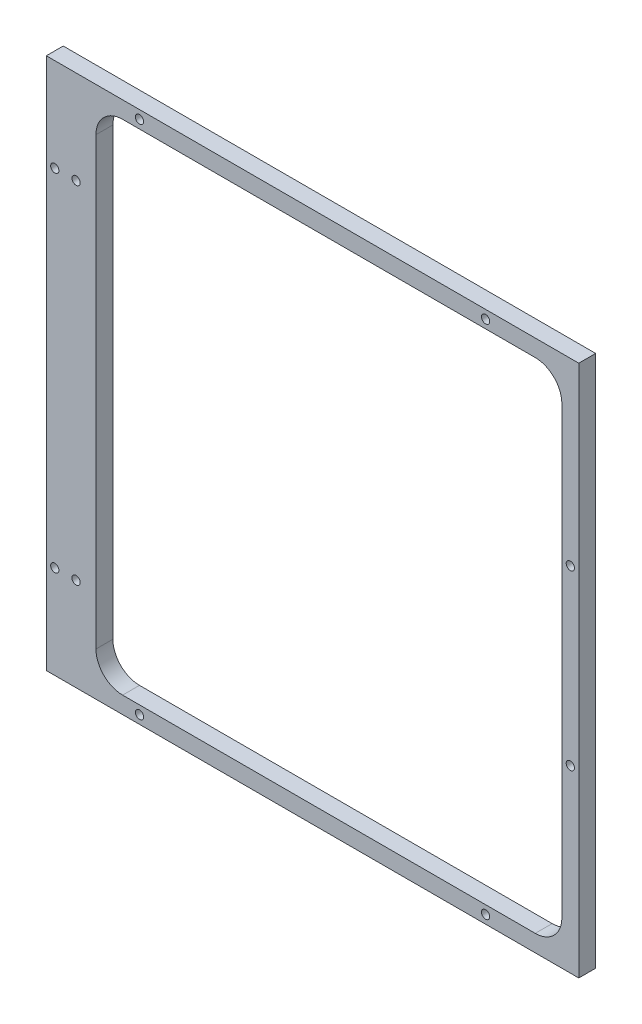
from build123d import *

# Parameters (mm, degrees)
SKETCH1_W           = 200
SKETCH1_H           = 200
BOSS_EXTRUDE1_DEPTH = 6.35
CUT_EXTRUDE1_DEPTH  = 6.35
SKETCH3_R           = 1.55
CUT_EXTRUDE2_DEPTH  = 6.35


with BuildPart() as part:
    # Sketch1 → Boss-Extrude1 (new body)
    with BuildSketch(Plane.XY):
        Rectangle(SKETCH1_W, SKETCH1_H)
    extrude(amount=BOSS_EXTRUDE1_DEPTH)

    # Sketch2 → Cut-Extrude1 (cut)
    with BuildSketch(Plane.XY.offset(6.35)):
        with BuildLine():
            Line((83.65, 93.65), (-71.35, 93.65))
            ThreePointArc((-71.35, 93.65), (-78.421067812, 90.721067812), (-81.35, 83.65))
            Line((-81.35, 83.65), (-81.35, -83.65))
            ThreePointArc((-81.35, -83.65), (-78.421067812, -90.721067812), (-71.35, -93.65))
            Line((-71.35, -93.65), (83.65, -93.65))
            ThreePointArc((83.65, -93.65), (90.721067812, -90.721067812), (93.65, -83.65))
            Line((93.65, -83.65), (93.65, 83.65))
            ThreePointArc((93.65, 83.65), (90.721067812, 90.721067812), (83.65, 93.65))
        make_face()
    extrude(amount=-CUT_EXTRUDE1_DEPTH, mode=Mode.SUBTRACT)

    # Sketch3 → Cut-Extrude2 (cut)
    with BuildSketch(Plane.XY.offset(6.35)):
        with Locations((-65, -96.825)):
            Circle(SKETCH3_R)
        with Locations((65, -96.825)):
            Circle(SKETCH3_R)
        with Locations((65, 96.825)):
            Circle(SKETCH3_R)
        with Locations((-65, 96.825)):
            Circle(SKETCH3_R)
        with Locations((96.825, 32.5)):
            Circle(SKETCH3_R)
        with Locations((96.825, -32.5)):
            Circle(SKETCH3_R)
        with Locations((-96.825, 65)):
            Circle(SKETCH3_R)
        with Locations((-88.825, 65)):
            Circle(SKETCH3_R)
        with Locations((-96.825, -65)):
            Circle(SKETCH3_R)
        with Locations((-88.825, -65)):
            Circle(SKETCH3_R)
        with BuildLine():
            Line((93.65, -83.65), (93.65, 83.65))
            ThreePointArc((93.65, 83.65), (90.721067812, 90.721067812), (83.65, 93.65))
            Line((83.65, 93.65), (-71.35, 93.65))
            ThreePointArc((-71.35, 93.65), (-78.421067812, 90.721067812), (-81.35, 83.65))
            Line((-81.35, 83.65), (-81.35, -83.65))
            ThreePointArc((-81.35, -83.65), (-78.421067812, -90.721067812), (-71.35, -93.65))
            Line((-71.35, -93.65), (83.65, -93.65))
            ThreePointArc((83.65, -93.65), (90.721067812, -90.721067812), (93.65, -83.65))
        make_face()
    extrude(amount=-CUT_EXTRUDE2_DEPTH, mode=Mode.SUBTRACT)


solid = part.part
